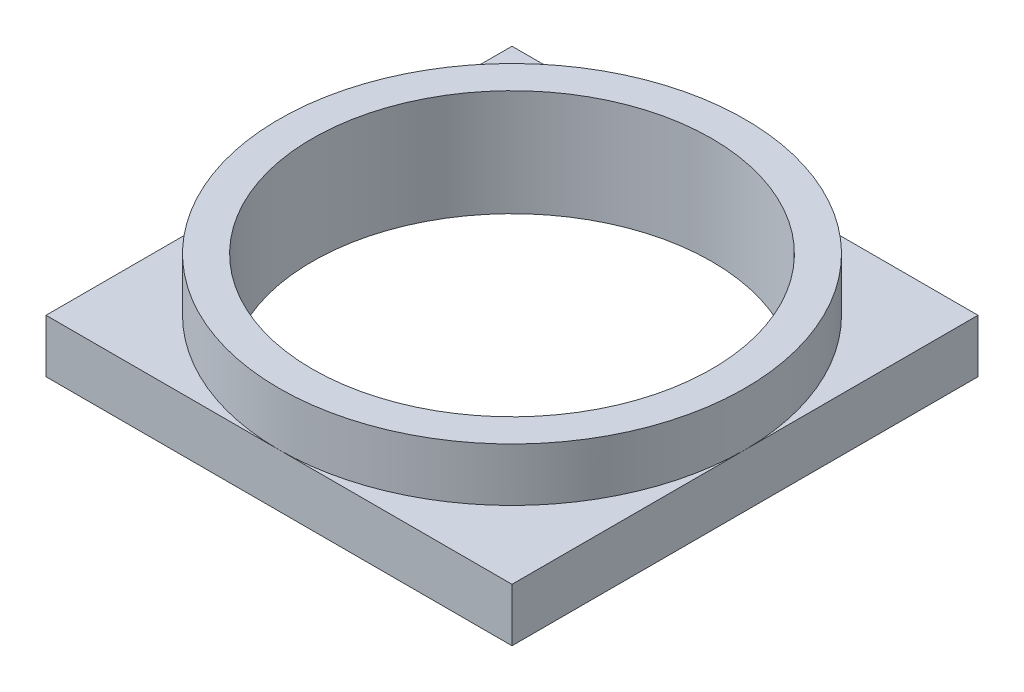
from build123d import *

# Parameters (mm, degrees)
SKETCH1_W           = 14
SKETCH1_H           = 14
BOSS_EXTRUDE1_DEPTH = 1.6
SKETCH2_R           = 7
SKETCH2_R_2         = 6
BOSS_EXTRUDE2_DEPTH = 1.6
SKETCH3_R           = 6
CUT_EXTRUDE1_DEPTH  = 2.6


with BuildPart() as part:
    # Sketch1 → Boss-Extrude1 (new body)
    with BuildSketch(Plane(origin=(0, 0, 0), x_dir=(1, 0, 0), z_dir=(0, 1, 0))):
        Rectangle(SKETCH1_W, SKETCH1_H)
    extrude(amount=BOSS_EXTRUDE1_DEPTH)

    # Sketch2 → Boss-Extrude2 (add)
    with BuildSketch(Plane(origin=(0, 1.6, 0), x_dir=(1, 0, 0), z_dir=(0, 1, 0))):
        Circle(SKETCH2_R)
        Circle(SKETCH2_R_2, mode=Mode.SUBTRACT)
    extrude(amount=BOSS_EXTRUDE2_DEPTH)

    # Sketch3 → Cut-Extrude1 (cut, through all)
    with BuildSketch(Plane(origin=(0, 1.6, 0), x_dir=(1, 0, 0), z_dir=(0, 1, 0))):
        Circle(SKETCH3_R)
    extrude(amount=-CUT_EXTRUDE1_DEPTH, mode=Mode.SUBTRACT)


solid = part.part
